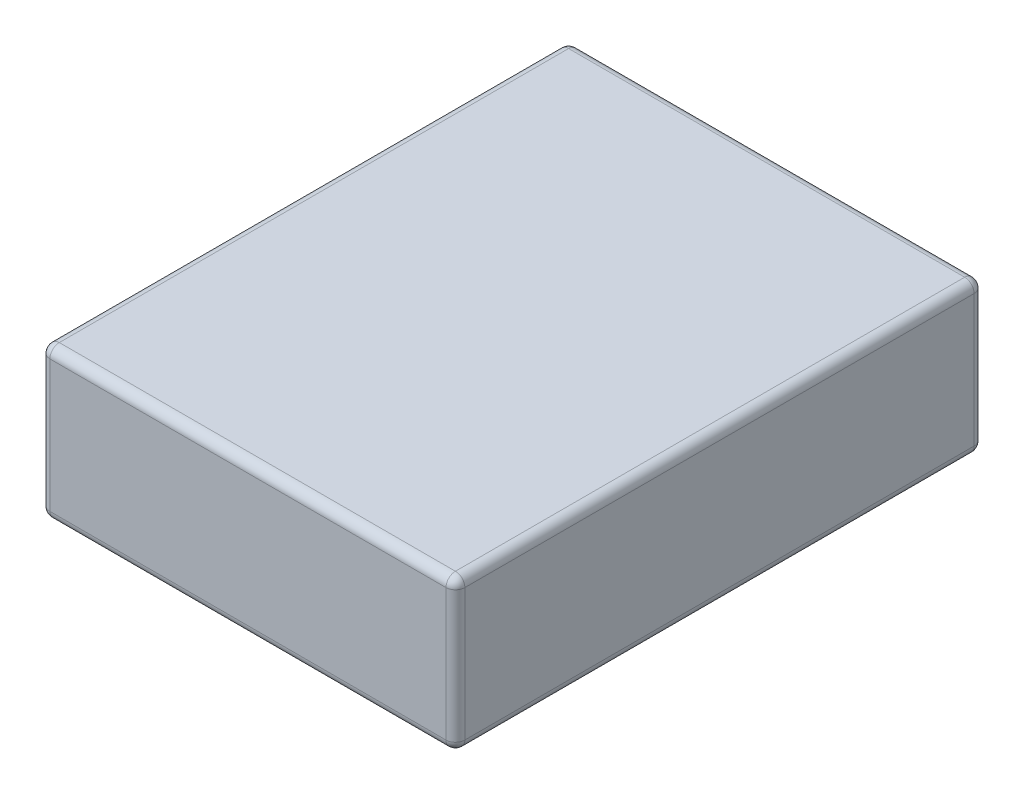
from build123d import *

# Parameters (mm, degrees)
SKETCH_1_W      = 22
SKETCH_1_H      = 28
EXTRUDE_1_DEPTH = 8
FILLET_1_R      = 0.5


with BuildPart() as part:
    # 草图1 → 凸台-拉伸1 (new body)
    with BuildSketch(Plane(origin=(0, 0, 0), x_dir=(1, 0, 0), z_dir=(0, 1, 0))):
        Rectangle(SKETCH_1_W, SKETCH_1_H)
    extrude(amount=EXTRUDE_1_DEPTH)

    # 圆角1
    fillet_1_edges = [part.edges().sort_by_distance(p)[0] for p in [
        (11, 8, 0),
        (0, 8, -14),
        (-11, 8, 0),
        (0, 0, -14),
        (11, 0, 0),
        (0, 0, 14),
        (-11, 0, 0),
        (-11, 4, -14),
        (11, 4, -14),
        (11, 4, 14),
        (-11, 4, 14),
        (0, 8, 14),
    ]]
    fillet(fillet_1_edges, radius=FILLET_1_R)


solid = part.part
